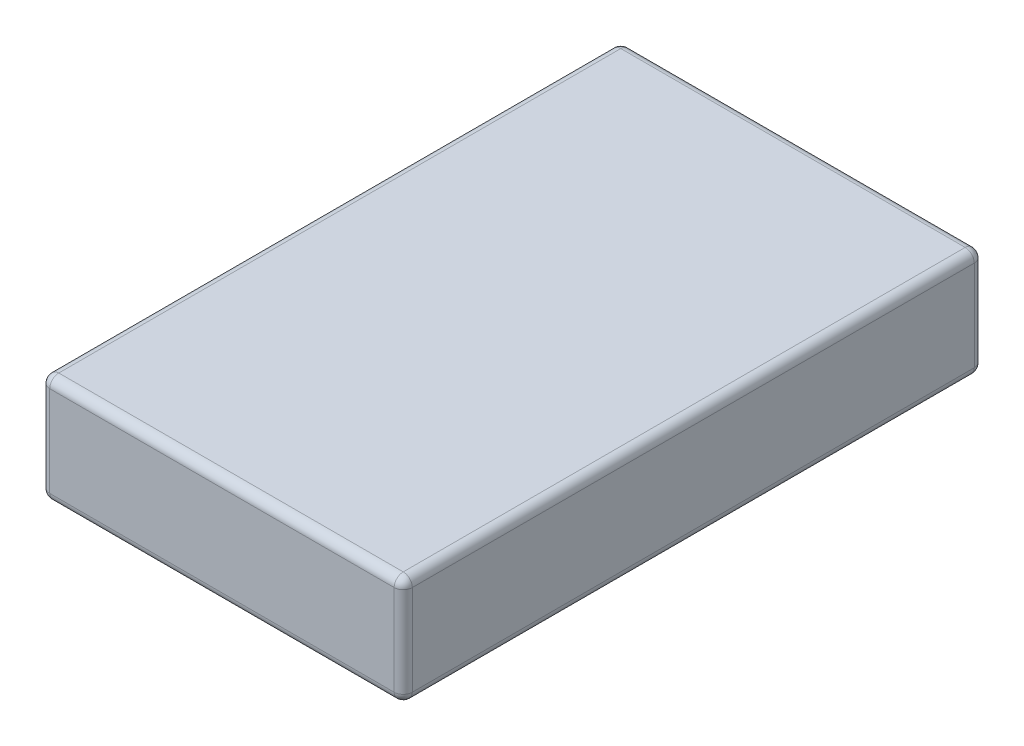
from build123d import *

# Parameters (mm, degrees)
SKETCH1_W           = 20
SKETCH1_H           = 32
BOSS_EXTRUDE1_DEPTH = 6
FILLET1_R           = 0.5


with BuildPart() as part:
    # Sketch1 → Boss-Extrude1 (new body)
    with BuildSketch(Plane(origin=(0, 0, 0), x_dir=(1, 0, 0), z_dir=(0, 1, 0))):
        Rectangle(SKETCH1_W, SKETCH1_H)
    extrude(amount=BOSS_EXTRUDE1_DEPTH)

    # Fillet1
    fillet1_edges = [part.edges().sort_by_distance(p)[0] for p in [
        (-10, 6, 0),
        (0, 6, 16),
        (10, 6, 0),
        (0, 0, 16),
        (-10, 0, 0),
        (0, 0, -16),
        (10, 0, 0),
        (10, 3, 16),
        (-10, 3, 16),
        (-10, 3, -16),
        (10, 3, -16),
        (0, 6, -16),
    ]]
    fillet(fillet1_edges, radius=FILLET1_R)


solid = part.part
